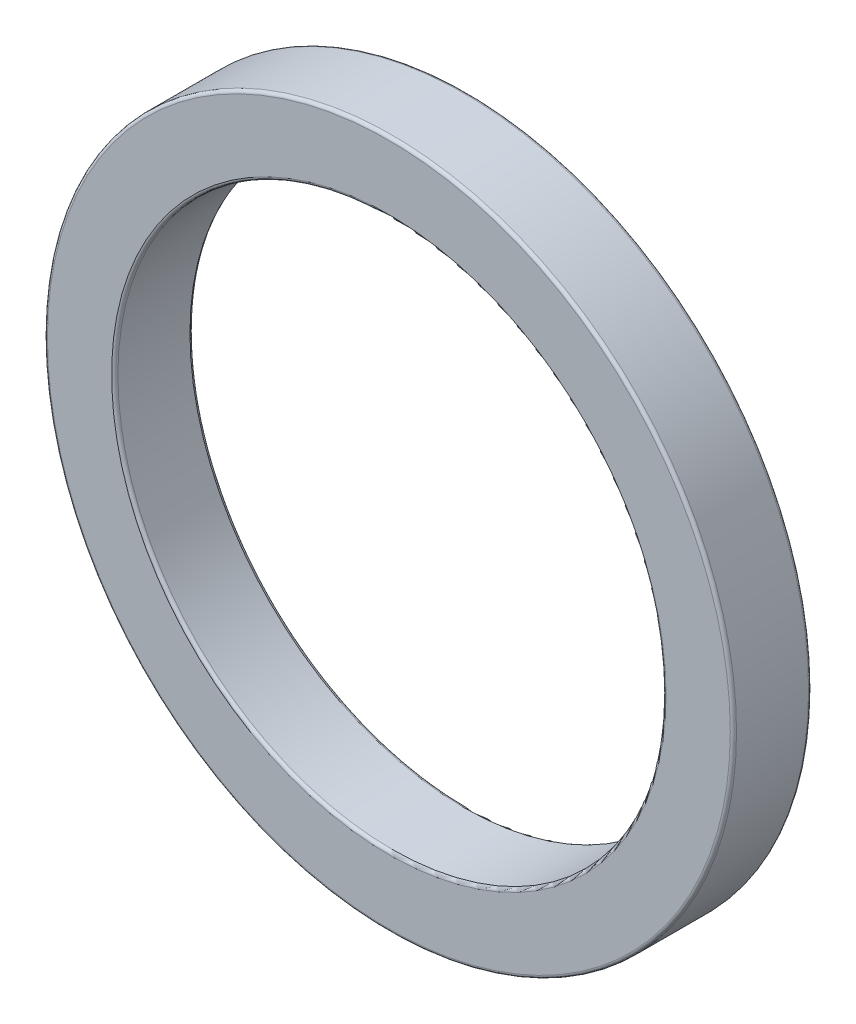
from build123d import *

# Parameters (mm, degrees)
SKETCH_1_R      = 22
SKETCH_1_R_2    = 17.5
EXTRUDE_1_DEPTH = 5
FILLET_1_R      = 0.2


with BuildPart() as part:
    # 草图1 → 凸台-拉伸1 (new body)
    with BuildSketch(Plane.XY):
        Circle(SKETCH_1_R)
        Circle(SKETCH_1_R_2, mode=Mode.SUBTRACT)
    extrude(amount=EXTRUDE_1_DEPTH)

    # 圆角1
    fillet_1_edges = [part.edges().sort_by_distance(p)[0] for p in [
        (-22, 0, 0),
        (-22, 0, 5),
        (-17.5, 0, 0),
        (-17.5, 0, 5),
    ]]
    fillet(fillet_1_edges, radius=FILLET_1_R)


solid = part.part
